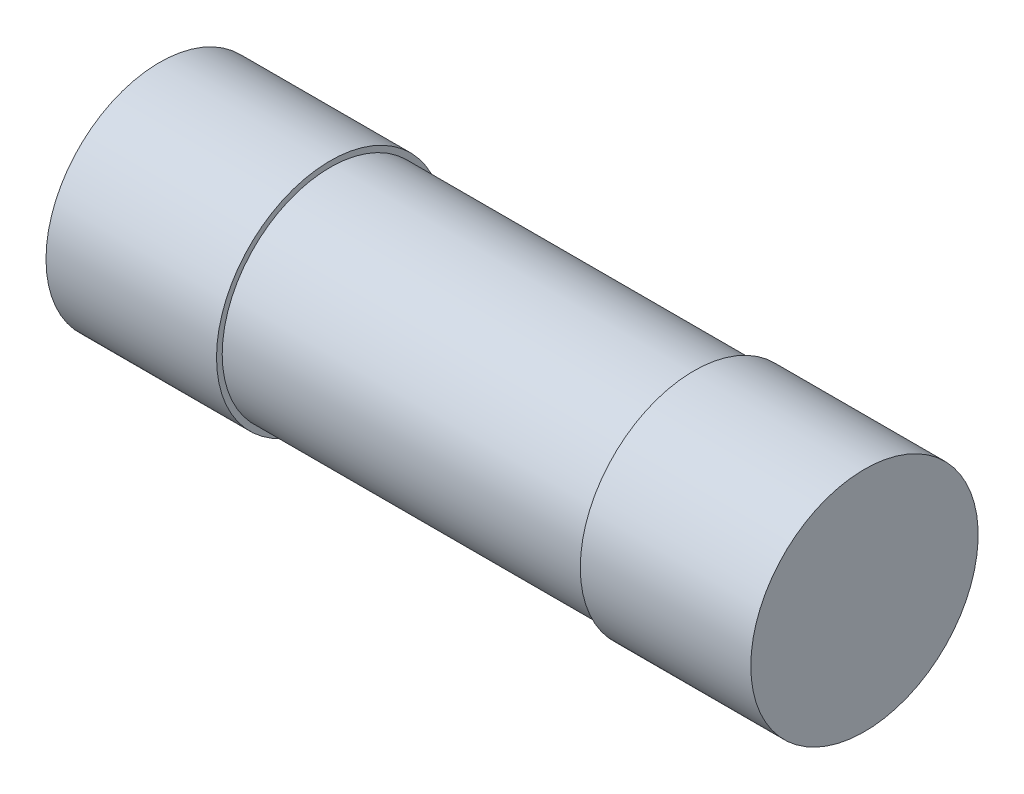
from build123d import *


with BuildPart() as part:
    # 草图1 → 旋转1 (revolve)
    with BuildSketch(Plane.XY):
        Polygon((0, 0), (0, 10), (15, 10), (15, 9.5), (47, 9.5), (47, 10), (62, 10), (62, 0), align=None)
    revolve(axis=Axis((-40.465116279, 0, 0), (1, 0, 0)))


solid = part.part
